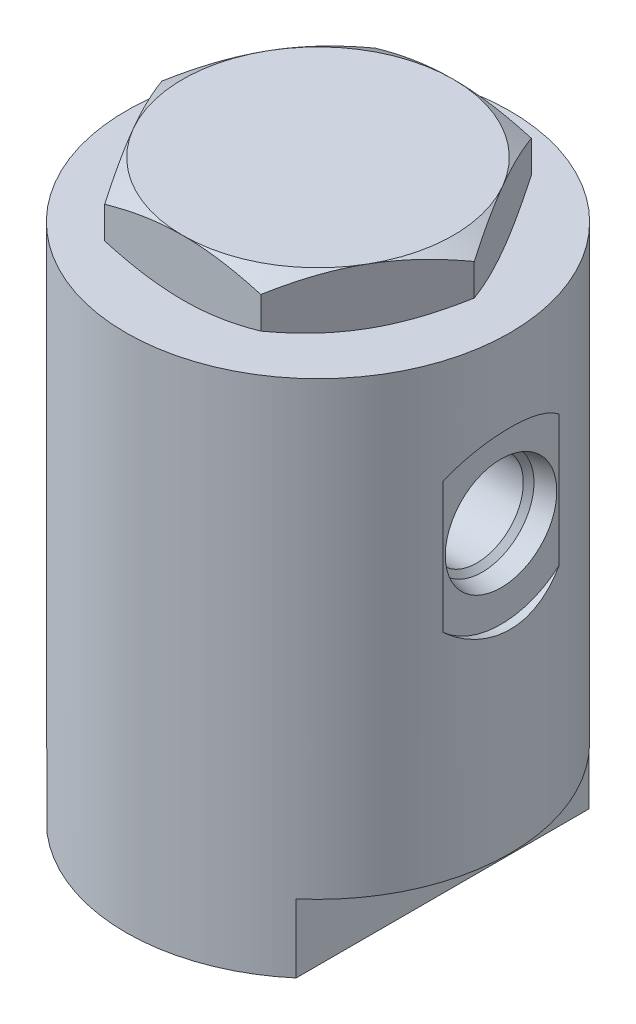
from build123d import *

# Parameters (mm, degrees)
SKETCH1_R          = 27.051
EXTRUDE1_DEPTH     = 73.152
CUT_EXTRUDE1_DEPTH = 9.652
EXTRUDE2_DEPTH     = 7.874
SKETCH7_W          = 15.875
SKETCH7_H          = 60.325


with BuildPart() as part:
    # Sketch1 → Extrude1 (new body)
    with BuildSketch(Plane(origin=(0, 0, 0), x_dir=(1, 0, 0), z_dir=(0, 1, 0))):
        with Locations(Location((0, 0, 0), (0, 0, 270))):  # turned: the seam where the file's is
            Circle(SKETCH1_R)
    extrude(amount=EXTRUDE1_DEPTH)

    # Sketch2 → Cut-Extrude1 (cut)
    with BuildSketch(Plane.XZ):
        with BuildLine():
            Line((17.526, 20.605725539), (17.526, -20.605725539))
            ThreePointArc((17.526, -20.605725539), (27.051, 0), (17.526, 20.605725539))
        make_face()
        with BuildLine():
            Line((-17.526, -20.605725539), (-17.526, 20.605725539))
            ThreePointArc((-17.526, 20.605725539), (-27.051, 0), (-17.526, -20.605725539))
        make_face()
    extrude(amount=-CUT_EXTRUDE1_DEPTH, mode=Mode.SUBTRACT)

    # S2D0007 → Cut-Revolve1 (revolve, cut)
    with BuildSketch(Plane(origin=(27.051, 49.276, 0), x_dir=(0, -1, 0), z_dir=(0, 0, 1)), mode=Mode.PRIVATE) as cut_revolve1_sk:
        Polygon((0, 0), (12.319, 0), (12.319, -1.27), (7.85495, -1.27), (7.290761118, -3.9243), (6.5405, -4.674561118), (6.5405, -16.7386), (0, -20.668528879), align=None)
    revolve(cut_revolve1_sk.sketch.rotate(Axis((-4.448190263, 49.276, 0), (1, 0, 0)), 270), axis=Axis((-4.448190263, 49.276, 0), (1, 0, 0)), mode=Mode.SUBTRACT)  # turned: the seam where the file's is

    # Sketch4 → Cut-Revolve2 (revolve, cut)
    with BuildSketch(Plane(origin=(0, 0, 0), x_dir=(-1, 0, 0), z_dir=(0, 0, 1)), mode=Mode.PRIVATE) as cut_revolve2_sk:
        Polygon((0, 0), (12.319, 0), (12.319, -0.254), (7.85495, -0.254), (7.290761118, -2.9083), (6.5405, -3.658561118), (6.5405, -15.7226), (0, -19.652528879), align=None)
    revolve(cut_revolve2_sk.sketch.rotate(Axis((0, 25.899297965, 0), (0, -1, 0)), 270), axis=Axis((0, 25.899297965, 0), (0, -1, 0)), mode=Mode.SUBTRACT)  # turned: the seam where the file's is

    # Sketch5 → Extrude2 (add)
    with BuildSketch(Plane(origin=(0, 73.152, 0), x_dir=(-1, 0, 0), z_dir=(0, 1, 0))):
        Polygon((21.997045256, 0), (10.998522628, 19.05), (-10.998522628, 19.05), (-21.997045256, 0), (-10.998522628, -19.05), (10.998522628, -19.05), align=None)
    extrude(amount=EXTRUDE2_DEPTH)

    # Sketch6 → Cut-Revolve3 (revolve, cut)
    with BuildSketch(Plane(origin=(0, 0, 0), x_dir=(0, 0, -1), z_dir=(1, 0, 0)), mode=Mode.PRIVATE) as cut_revolve3_sk:
        Polygon((19.05, 81.026), (25.869084029, 77.089), (19.05, 73.152), (31.75, 73.152), (31.75, 81.026), align=None)
    revolve(cut_revolve3_sk.sketch.rotate(Axis((0, 72.7583, 0), (0, 1, 0)), 180), axis=Axis((0, 72.7583, 0), (0, 1, 0)), mode=Mode.SUBTRACT)  # turned: the seam where the file's is

    # Sketch7 → Cut-Revolve4 (revolve, cut)
    with BuildSketch(Plane.XY, mode=Mode.PRIVATE) as cut_revolve4_sk:
        with Locations((-7.9375, 42.9895)):
            Rectangle(SKETCH7_W, SKETCH7_H)
    revolve(cut_revolve4_sk.sketch.rotate(Axis((0, 0, 0), (0, 1, 0)), 90), axis=Axis((0, 0, 0), (0, 1, 0)), mode=Mode.SUBTRACT)  # turned: the seam where the file's is


solid = part.part
